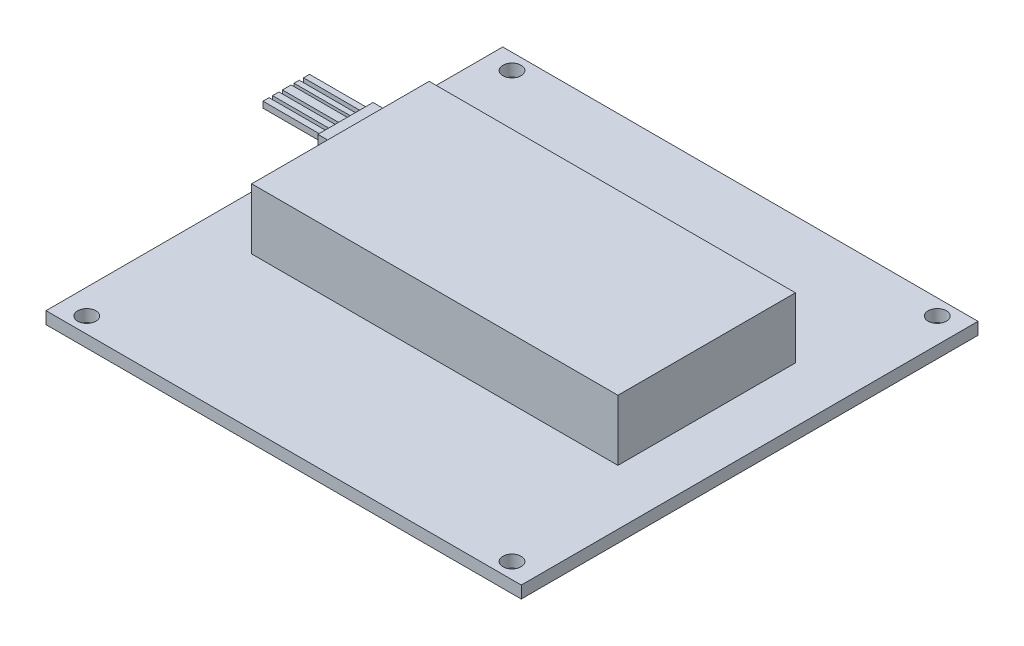
from build123d import *

# Parameters (mm, degrees)
SKETCH_2_W      = 78.232
SKETCH_2_H      = 75.184
SKETCH_2_R      = 1.5
EXTRUDE_1_DEPTH = 2
SKETCH_4_W      = 60.289914042
SKETCH_4_H      = 29.214557113
EXTRUDE_2_DEPTH = 10
SKETCH_5_W      = 9.086617177
SKETCH_5_H      = 2.41728743
EXTRUDE_3_DEPTH = 4
SKETCH_6_W      = 0.859863671
SKETCH_6_H      = 1.050944487
SKETCH_6_W_2    = 1.433106119
SKETCH_6_H_2    = 1.003174283
SKETCH_6_W_3    = 1.050944487
SKETCH_6_W_4    = 1.003174283
SKETCH_6_W_5    = 0.983317738
EXTRUDE_4_DEPTH = 10


with BuildPart() as part:
    # 草图2 → 凸台-拉伸1 (new body)
    with BuildSketch(Plane(origin=(0, 0, 0), x_dir=(1, 0, 0), z_dir=(0, 1, 0))):
        Rectangle(SKETCH_2_W, SKETCH_2_H)
        with Locations((35, -35)):
            Circle(SKETCH_2_R, mode=Mode.SUBTRACT)
        with Locations((35, 35)):
            Circle(SKETCH_2_R, mode=Mode.SUBTRACT)
        with Locations((-35, 35)):
            Circle(SKETCH_2_R, mode=Mode.SUBTRACT)
        with Locations((-35, -35)):
            Circle(SKETCH_2_R, mode=Mode.SUBTRACT)
    extrude(amount=EXTRUDE_1_DEPTH)

    # 草图4 → 凸台-拉伸2 (add)
    with BuildSketch(Plane(origin=(0, 2, 0), x_dir=(1, 0, 0), z_dir=(0, 1, 0))):
        with Locations((-0.127049012, 2.027434591)):
            Rectangle(SKETCH_4_W, SKETCH_4_H)
    extrude(amount=EXTRUDE_2_DEPTH)

    # 草图5 → 凸台-拉伸3 (add)
    with BuildSketch(Plane.ZY.offset(30.272006033)):
        with Locations((-6.851231395, 8.39841401)):
            Rectangle(SKETCH_5_W, SKETCH_5_H)
    extrude(amount=EXTRUDE_3_DEPTH)

    # 草图6 → 凸台-拉伸4 (add)
    with BuildSketch(Plane.ZY.offset(34.272006033)):
        with Locations((-8.824134234, 8.322199757)):
            Rectangle(SKETCH_6_W, SKETCH_6_H)
        with Locations((-7.199947299, 8.346084859)):
            Rectangle(SKETCH_6_W_2, SKETCH_6_H_2)
        with Locations((-5.384679549, 8.346084859)):
            Rectangle(SKETCH_6_W_3, SKETCH_6_H_2)
        with Locations((-3.784377716, 8.346084859)):
            Rectangle(SKETCH_6_W_4, SKETCH_6_H_2)
        with Locations((-10.446641143, 8.322199757)):
            Rectangle(SKETCH_6_W_5, SKETCH_6_H)
    extrude(amount=EXTRUDE_4_DEPTH)


solid = part.part
